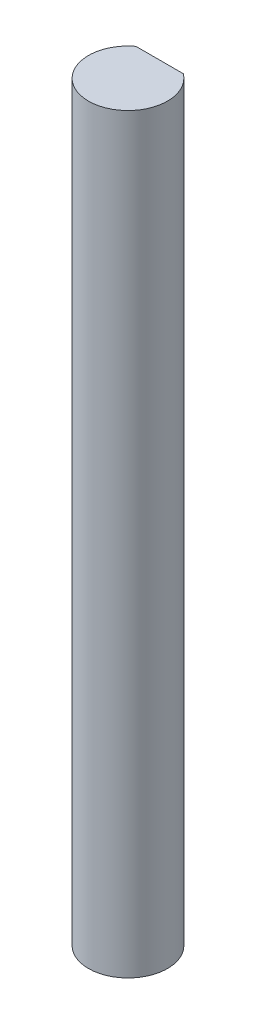
from build123d import *

# Parameters (mm, degrees)
BOSS_EXTRUDE1_DEPTH = 60.325


with BuildPart() as part:
    # Sketch1 → Boss-Extrude1 (new body)
    with BuildSketch(Plane(origin=(0, 0, 0), x_dir=(1, 0, 0), z_dir=(0, 1, 0))):
        with BuildLine():
            Line((-1.905, 2.54), (1.905, 2.54))
            ThreePointArc((1.905, 2.54), (0, -3.175), (-1.905, 2.54))
        make_face()
    extrude(amount=BOSS_EXTRUDE1_DEPTH)


solid = part.part
